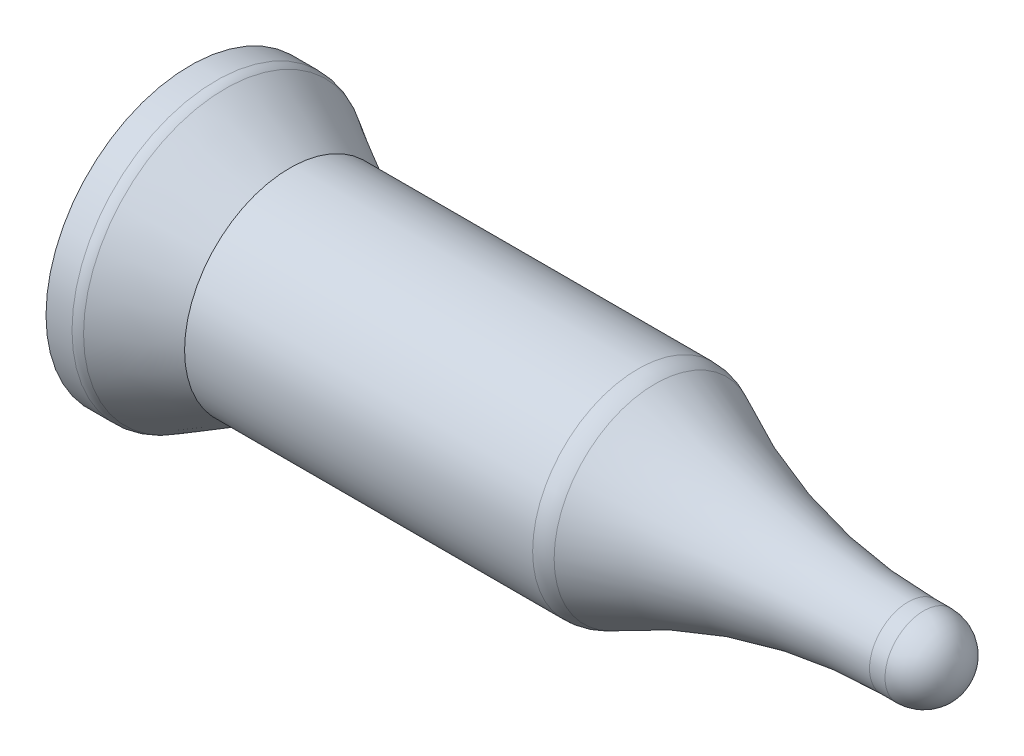
from build123d import *


with BuildPart() as part:
    # Sketch1 → Revolve2 (revolve)
    with BuildSketch(Plane.XY, mode=Mode.PRIVATE) as revolve2_sk:
        with BuildLine():
            Line((1.496304491, 5.9309), (1.496304491, 0))
            Line((1.496304491, 0), (31.087304489, 0))
            Line((31.087304489, 0), (31.658804491, 0))
            Line((31.658804491, 0), (32.230304494, 0))
            Line((32.230304494, 0), (33.246304491, 0))
            ThreePointArc((33.246304491, 0), (32.781336507, 1.122532015), (31.658804491, 1.5875))
            Line((31.658804491, 1.5875), (31.021091308, 1.5875))
            ThreePointArc((31.021091308, 1.5875), (25.663749675, 2.239020867), (20.618721916, 4.155602128))
            ThreePointArc((20.618721916, 4.155602128), (20.27474275, 4.286278123), (19.909469457, 4.3307))
            Line((19.909469457, 4.3307), (5.594648416, 4.3307))
            Line((5.594648416, 4.3307), (2.940913387, 5.83211104))
            ThreePointArc((2.940913387, 5.83211104), (2.759693318, 5.905789005), (2.565686634, 5.9309))
            Line((2.565686634, 5.9309), (1.496304491, 5.9309))
        make_face()
    revolve(revolve2_sk.sketch.rotate(Axis((0, 0, 0), (1, 0, 0)), 90), axis=Axis((0, 0, 0), (1, 0, 0)))  # turned: the seam where the file's is


solid = part.part
